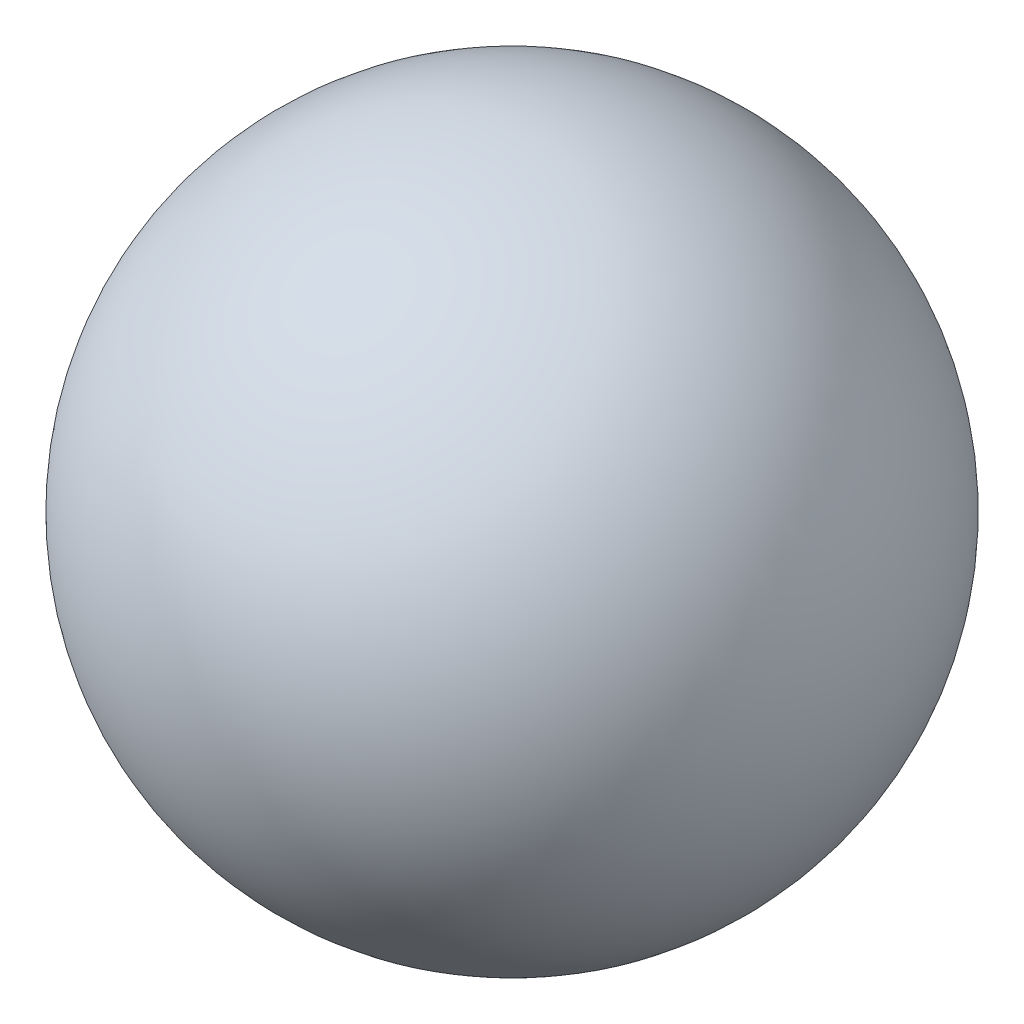
from build123d import *


with BuildPart() as part:
    # Esquisse1 → Révolution2 (revolve)
    with BuildSketch(Plane.XY):
        with BuildLine():
            Line((0, 1.5), (0, -1.5))
            ThreePointArc((0, -1.5), (-1.5, 0), (0, 1.5))
        make_face()
    revolve(axis=Axis((0, 1.5, 0), (0, -1, 0)))


solid = part.part
